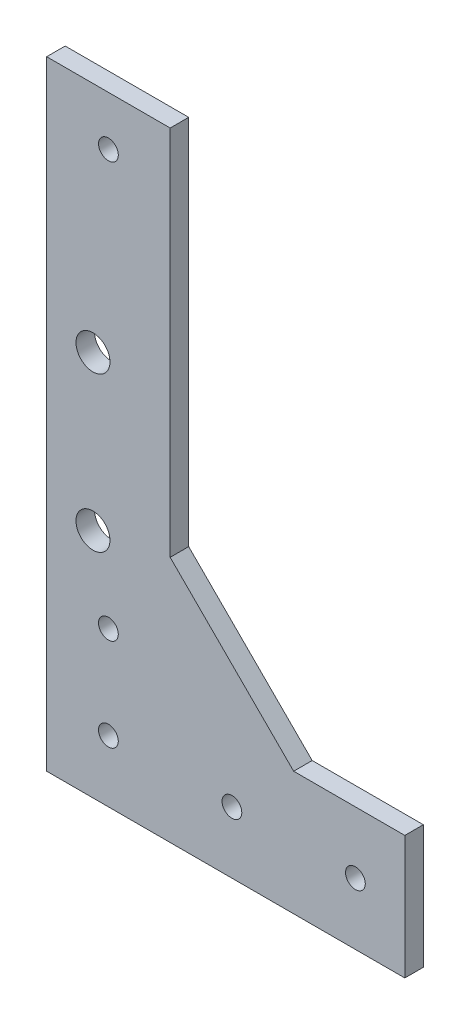
from build123d import *

# Parameters (mm, degrees)
EXTRUDE1_DEPTH     = 3
SKETCH2_R          = 1.6
SKETCH2_R_2        = 2.75
CUT_EXTRUDE1_DEPTH = 3


with BuildPart() as part:
    # Sketch1 → Extrude1 (new body)
    with BuildSketch(Plane.XY):
        Polygon((-195.489923187, -7.502951786), (-195.489923187, -27.502951786), (-253.489921235, -27.502951786), (-253.489921235, 72.709593142), (-233.489921235, 72.709593142), (-233.489921235, 12.497048214), (-213.489921235, -7.502951786), align=None)
    extrude(amount=EXTRUDE1_DEPTH)

    # Sketch2 → Cut-Extrude1 (cut)
    with BuildSketch(Plane.XY.offset(3)):
        with Locations((-203.489923187, -17.502951786)):
            Circle(SKETCH2_R)
        with Locations((-223.489923187, -17.502951786)):
            Circle(SKETCH2_R)
        with Locations((-243.489923187, -17.502951786)):
            Circle(SKETCH2_R)
        with Locations((-243.489923187, -2.502951786)):
            Circle(SKETCH2_R)
        with Locations((-245.989921235, 9.997448214)):
            Circle(SKETCH2_R_2)
        with Locations((-245.989921235, 34.997448214)):
            Circle(SKETCH2_R_2)
        with Locations((-243.489923187, 64.709593142)):
            Circle(SKETCH2_R)
    extrude(amount=-CUT_EXTRUDE1_DEPTH, mode=Mode.SUBTRACT)


solid = part.part
